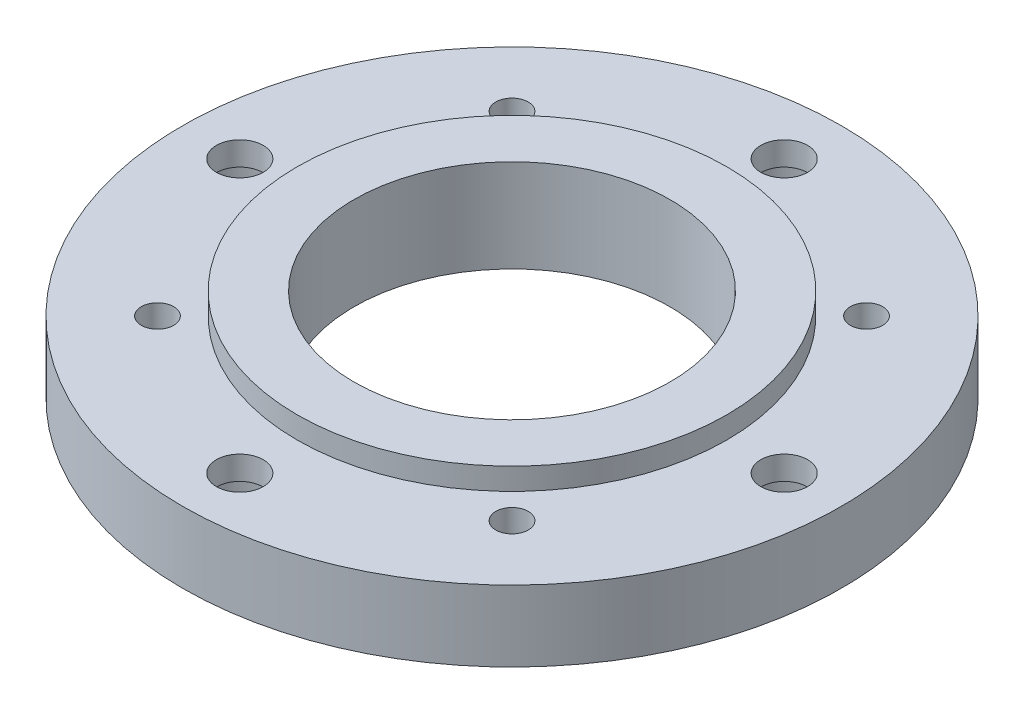
from build123d import *

# Parameters (mm, degrees)
SKETCH1_R                                           = 22.987
SKETCH1_R_2                                         = 11.0236
BOSS_EXTRUDE1_DEPTH                                 = 4.953
SKETCH1_3_R                                         = 14.986
SKETCH1_3_R_2                                       = 11.0236
BOSS_EXTRUDE2_DEPTH                                 = 6.477
F_4_40_TAPPED_HOLE1_D                               = 2.2606
CBORE_FOR_4_BINDING_HEAD_MACHINE_SCREW1_D           = 3.2639
CBORE_FOR_4_BINDING_HEAD_MACHINE_SCREW1_CBORE_D     = 6.74624
CBORE_FOR_4_BINDING_HEAD_MACHINE_SCREW1_CBORE_DEPTH = 3.302


with BuildPart() as part:
    # Sketch1 → Boss-Extrude1 (new body)
    with BuildSketch(Plane(origin=(0, 0, 0), x_dir=(1, 0, 0), z_dir=(0, 1, 0))):
        Circle(SKETCH1_R)
        Circle(SKETCH1_R_2, mode=Mode.SUBTRACT)
    extrude(amount=BOSS_EXTRUDE1_DEPTH)

    # Sketch1_3 → Boss-Extrude2 (add)
    with BuildSketch(Plane(origin=(0, 0, 0), x_dir=(1, 0, 0), z_dir=(0, 1, 0))):
        Circle(SKETCH1_3_R)
        Circle(SKETCH1_3_R_2, mode=Mode.SUBTRACT)
    extrude(amount=BOSS_EXTRUDE2_DEPTH)

    # 4-40 Tapped Hole1 (through all)
    with Locations(Plane(origin=(-12.364822729, 4.953, -12.364822729), x_dir=(0, 0, 1), z_dir=(0, 1, 0))):
        with Locations((0, 0), (0, 24.729645458), (24.729645458, 24.729645458), (24.729645458, 0)):
            Hole(F_4_40_TAPPED_HOLE1_D / 2)

    # CBORE for _4 Binding Head Machine Screw1 (through all)
    with Locations(Plane(origin=(0, 0, -18.9865), x_dir=(0, 0, -1), z_dir=(0, -1, 0))):
        with Locations((0, 0), (-18.9865, -18.9865), (-37.973, 0), (-18.9865, 18.9865)):
            CounterBoreHole(CBORE_FOR_4_BINDING_HEAD_MACHINE_SCREW1_D / 2, CBORE_FOR_4_BINDING_HEAD_MACHINE_SCREW1_CBORE_D / 2, CBORE_FOR_4_BINDING_HEAD_MACHINE_SCREW1_CBORE_DEPTH)


solid = part.part
